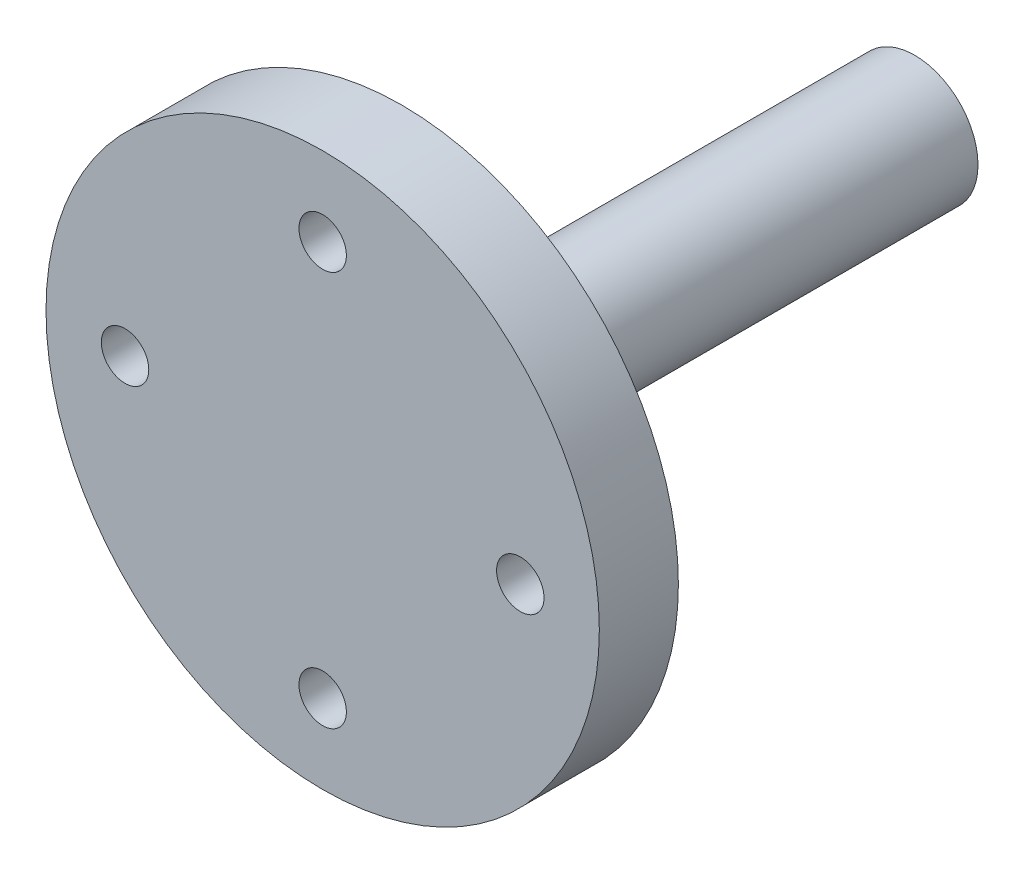
from build123d import *

# Parameters (mm, degrees)
SKETCH1_R                = 4
BOSS_EXTRUDE1_DEPTH      = 12.451061179
BOSS_EXTRUDE1_DEPTH_BACK = 20
SKETCH3_R                = 17.5
SKETCH3_R_2              = 1.5
BOSS_EXTRUDE2_DEPTH      = 5
FILLET1_R                = 3


with BuildPart() as part:
    # Sketch1 → Boss-Extrude1 (new body, two sides)
    with BuildSketch(Plane.XY) as boss_extrude1_sk:
        Circle(SKETCH1_R)
    extrude(amount=BOSS_EXTRUDE1_DEPTH)
    extrude(boss_extrude1_sk.sketch, amount=-BOSS_EXTRUDE1_DEPTH_BACK)

    # Sketch3 → Boss-Extrude2 (add)
    with BuildSketch(Plane.XY.offset(12.451061179)):
        Circle(SKETCH3_R)
        with Locations((0, 12.5)):
            Circle(SKETCH3_R_2, mode=Mode.SUBTRACT)
        with Locations((12.5, 0)):
            Circle(SKETCH3_R_2, mode=Mode.SUBTRACT)
        with Locations((0, -12.5)):
            Circle(SKETCH3_R_2, mode=Mode.SUBTRACT)
        with Locations((-12.5, 0)):
            Circle(SKETCH3_R_2, mode=Mode.SUBTRACT)
    extrude(amount=BOSS_EXTRUDE2_DEPTH)

    # Fillet1
    fillet1_edges = [part.edges().sort_by_distance(p)[0] for p in [
        (-4, 0, 12.451061179),
    ]]
    fillet(fillet1_edges, radius=FILLET1_R)


solid = part.part
